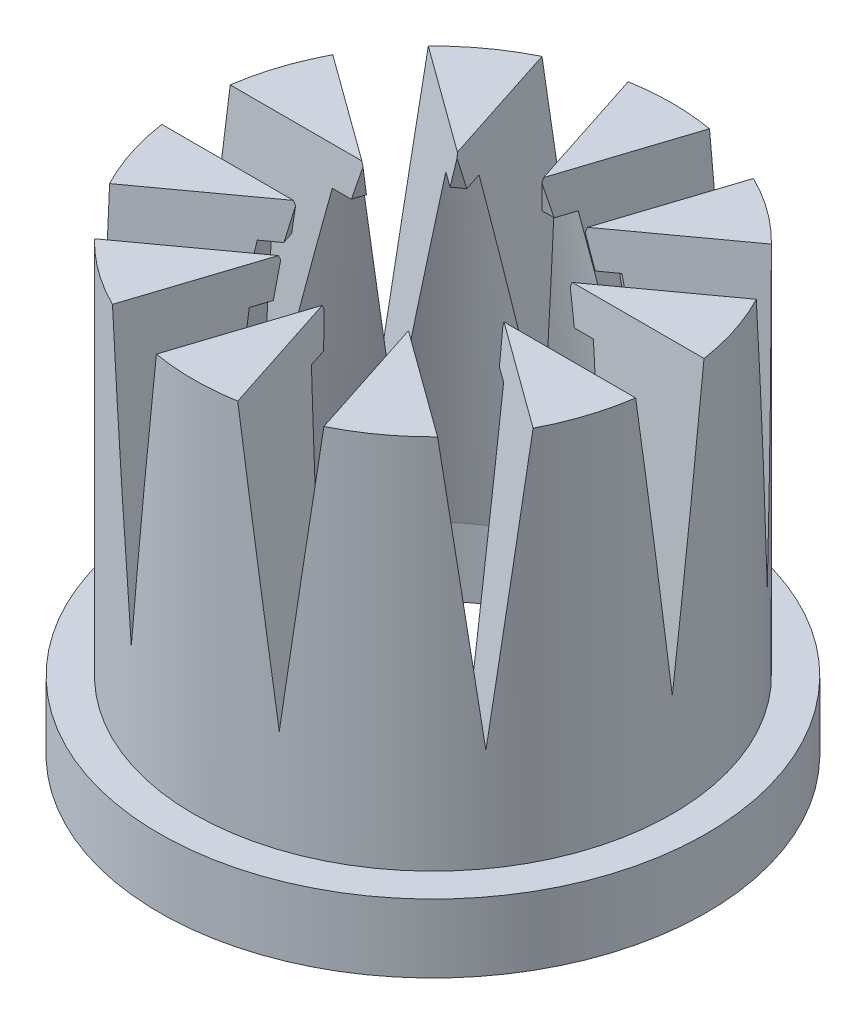
from build123d import *

# Parameters (mm, degrees)
SKETCH1_R           = 3.5
BOSS_EXTRUDE1_DEPTH = 5.5
SKETCH2_R           = 2.75
CUT_EXTRUDE1_DEPTH  = 5.5
CUT_EXTRUDE1_TAPER  = 12
CUT_EXTRUDE2_DEPTH  = 5.5
CIRPATTERN1_COUNT   = 10
SKETCH4_R           = 2.75
CUT_EXTRUDE3_DEPTH  = 5
CUT_EXTRUDE3_TAPER  = 9
SKETCH5_R           = 4
SKETCH5_R_2         = 3.5
SKETCH5_R_3         = 2.75
BOSS_EXTRUDE2_DEPTH = 1


with BuildPart() as part:
    # Sketch1 → Boss-Extrude1 (new body)
    with BuildSketch(Plane(origin=(0, 0, 0), x_dir=(1, 0, 0), z_dir=(0, 1, 0))):
        Circle(SKETCH1_R)
    extrude(amount=BOSS_EXTRUDE1_DEPTH)

    # Sketch2 → Cut-Extrude1 (cut)
    with BuildSketch(Plane.XZ):
        Circle(SKETCH2_R)
    extrude(amount=-CUT_EXTRUDE1_DEPTH, taper=CUT_EXTRUDE1_TAPER, mode=Mode.SUBTRACT)

    # Sketch3 → Cut-Extrude2 (cut)
    with BuildSketch(Plane(origin=(0, 0, 0), x_dir=(0, 0, -1), z_dir=(1, 0, 0))):
        Polygon((-0.5, 5.5), (-0.35, 4.3), (0, 1.5), (0.35, 4.3), (0.5, 5.5), align=None)
    cut_extrude2 = extrude(amount=-CUT_EXTRUDE2_DEPTH, mode=Mode.SUBTRACT)

    # CirPattern1: Cut-Extrude2 ×10 about axis
    cirpattern1_axis = Axis((0, 5.5, 0), (0, -1, 0))
    for i in range(1, CIRPATTERN1_COUNT):
        add(cut_extrude2.rotate(cirpattern1_axis, i * 360 / CIRPATTERN1_COUNT), mode=Mode.SUBTRACT)

    # Sketch4 → Cut-Extrude3 (cut)
    with BuildSketch(Plane.XZ):
        Circle(SKETCH4_R)
    extrude(amount=-CUT_EXTRUDE3_DEPTH, taper=CUT_EXTRUDE3_TAPER, mode=Mode.SUBTRACT)

    # Sketch5 → Boss-Extrude2 (add)
    with BuildSketch(Plane.XZ):
        Circle(SKETCH5_R)
        Circle(SKETCH5_R_2, mode=Mode.SUBTRACT)
        Circle(SKETCH5_R_2)
        Circle(SKETCH5_R_3, mode=Mode.SUBTRACT)
    extrude(amount=BOSS_EXTRUDE2_DEPTH)


solid = part.part
